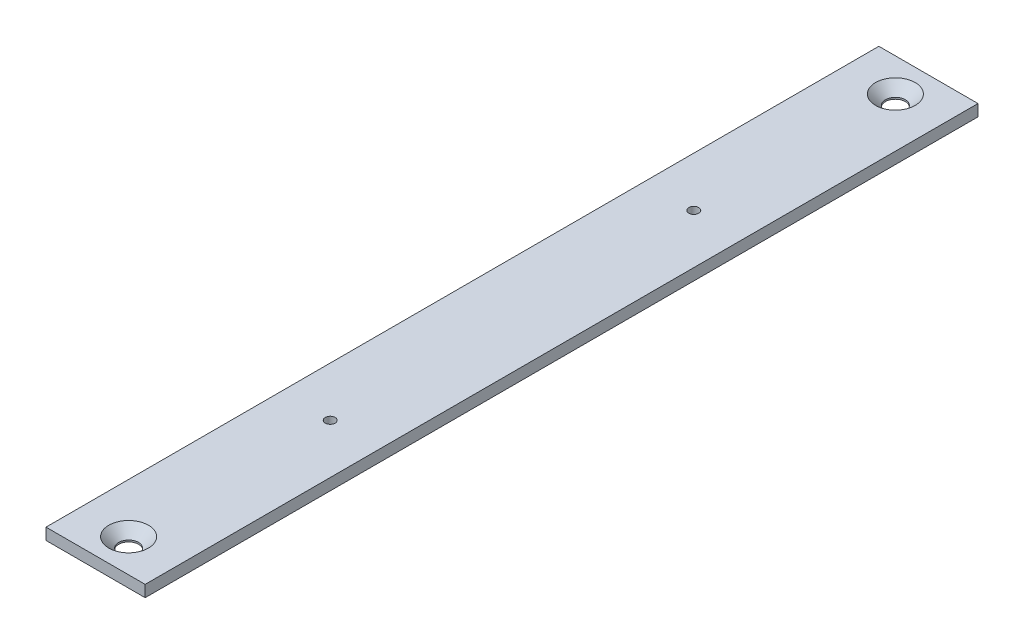
from build123d import *

# Parameters (mm, degrees)
SKETCH1_W           = 30
SKETCH1_H           = 252
BOSS_EXTRUDE1_DEPTH = 3.5
SKETCH2_R           = 1.5
SKETCH2_R_2         = 3
CUT_EXTRUDE1_DEPTH  = 3.5
CHAMFER1_SIZE       = 3


with BuildPart() as part:
    # Sketch1 → Boss-Extrude1 (new body)
    with BuildSketch(Plane(origin=(0, 0, 0), x_dir=(1, 0, 0), z_dir=(0, 1, 0))):
        Rectangle(SKETCH1_W, SKETCH1_H)
    extrude(amount=BOSS_EXTRUDE1_DEPTH)

    # Sketch2 → Cut-Extrude1 (cut)
    with BuildSketch(Plane(origin=(0, 3.5, 0), x_dir=(1, 0, 0), z_dir=(0, 1, 0))):
        with Locations((0, 55)):
            Circle(SKETCH2_R)
        with Locations((0, -55)):
            Circle(SKETCH2_R)
        with Locations((0, 116)):
            Circle(SKETCH2_R_2)
        with Locations((0, -116)):
            Circle(SKETCH2_R_2)
    extrude(amount=-CUT_EXTRUDE1_DEPTH, mode=Mode.SUBTRACT)

    # Chamfer1
    chamfer1_edges = [part.edges().sort_by_distance(p)[0] for p in [
        (-3, 3.5, 116),
        (-3, 3.5, -116),
    ]]
    chamfer(chamfer1_edges, length=CHAMFER1_SIZE)


solid = part.part
